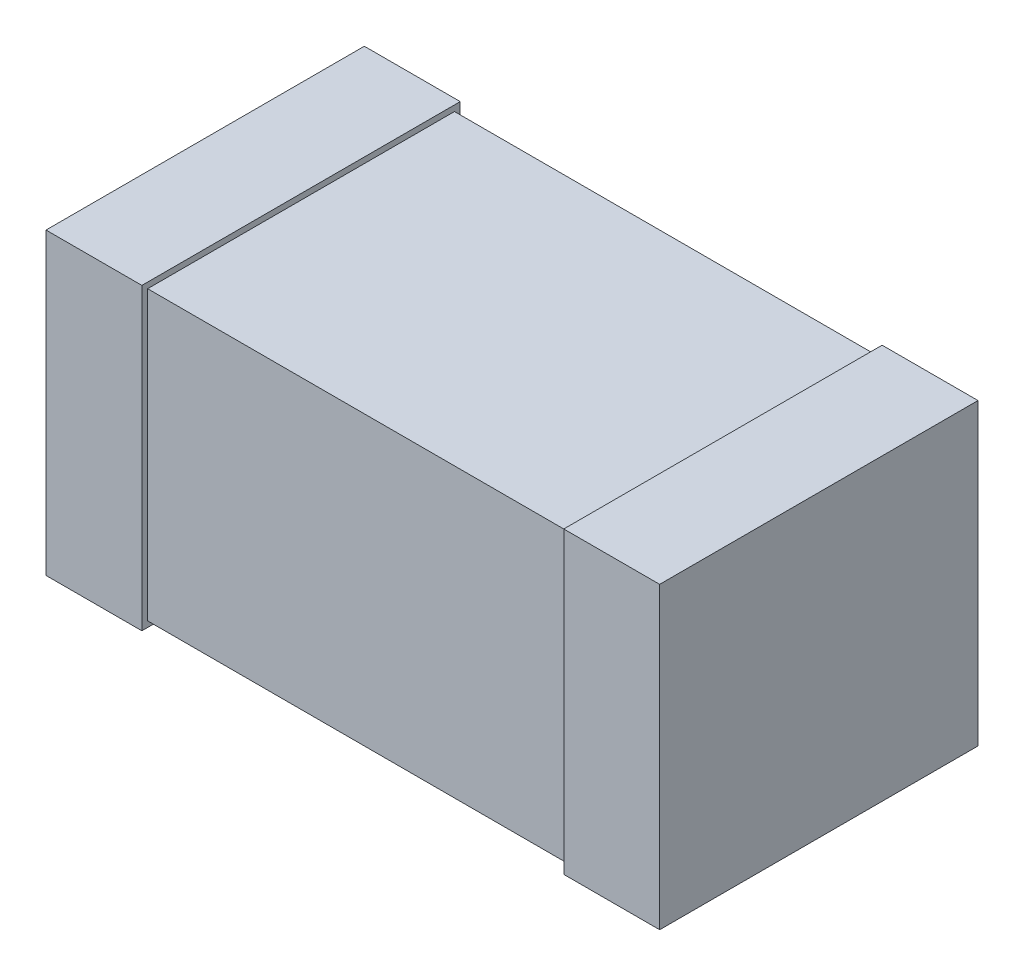
from build123d import *

# Parameters (mm, degrees)
SKETCH1_W           = 3.2
SKETCH1_H           = 1.6
EXTRUDE1_DEPTH      = 1.5
SKETCH2_W           = 0.5
SKETCH2_H           = 1.56
EXTRUDE2_DEPTH      = 0.83
EXTRUDE2_DEPTH_BACK = 0.83


with BuildPart() as part:
    # Sketch1 → Extrude1 (new body)
    with BuildSketch(Plane(origin=(0, 0, 0), x_dir=(1, 0, 0), z_dir=(0, 1, 0))):
        Rectangle(SKETCH1_W, SKETCH1_H)
    extrude(amount=EXTRUDE1_DEPTH)

    # Sketch2 → Extrude2 (add, two sides)
    with BuildSketch(Plane.XY) as extrude2_sk:
        with Locations((-1.35, 0.75)):
            Rectangle(SKETCH2_W, SKETCH2_H)
        with Locations((1.35, 0.75)):
            Rectangle(SKETCH2_W, SKETCH2_H)
    extrude(amount=EXTRUDE2_DEPTH)
    extrude(extrude2_sk.sketch, amount=-EXTRUDE2_DEPTH_BACK)


solid = part.part
